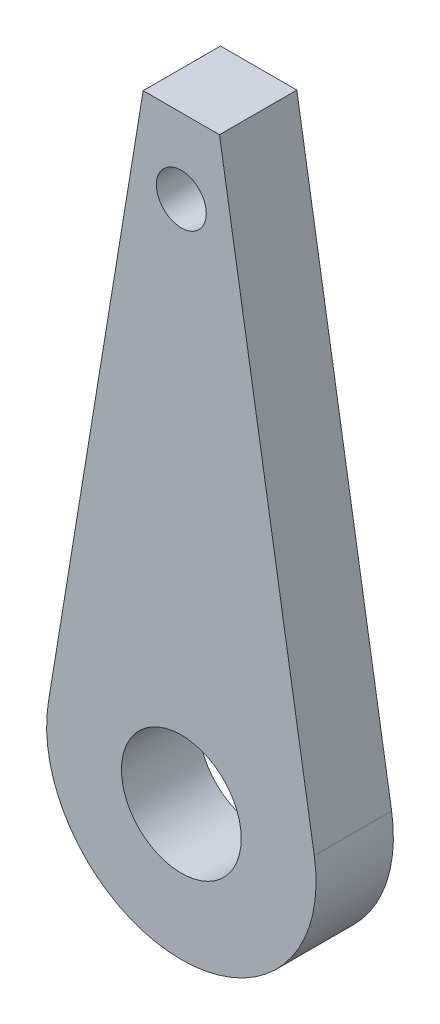
from build123d import *

# Parameters (mm, degrees)
SKETCH1_R           = 2.4
SKETCH1_R_2         = 1
BOSS_EXTRUDE1_DEPTH = 3.1


with BuildPart() as part:
    # Sketch1 → Boss-Extrude1 (new body)
    with BuildSketch(Plane.XY):
        with BuildLine():
            Line((-20.581998731, 60.620734864), (-17.522774409, 60.620734864))
            Line((-17.522774409, 60.620734864), (-13.723813298, 37.496124427))
            ThreePointArc((-13.723813298, 37.496124427), (-19.05238657, 31.220734864), (-24.380959842, 37.496124427))
            Line((-24.380959842, 37.496124427), (-20.581998731, 60.620734864))
        make_face()
        with Locations((-19.05238657, 36.620734864)):
            Circle(SKETCH1_R, mode=Mode.SUBTRACT)
        with Locations((-19.05238657, 57.620734864)):
            Circle(SKETCH1_R_2, mode=Mode.SUBTRACT)
    extrude(amount=BOSS_EXTRUDE1_DEPTH)


solid = part.part
